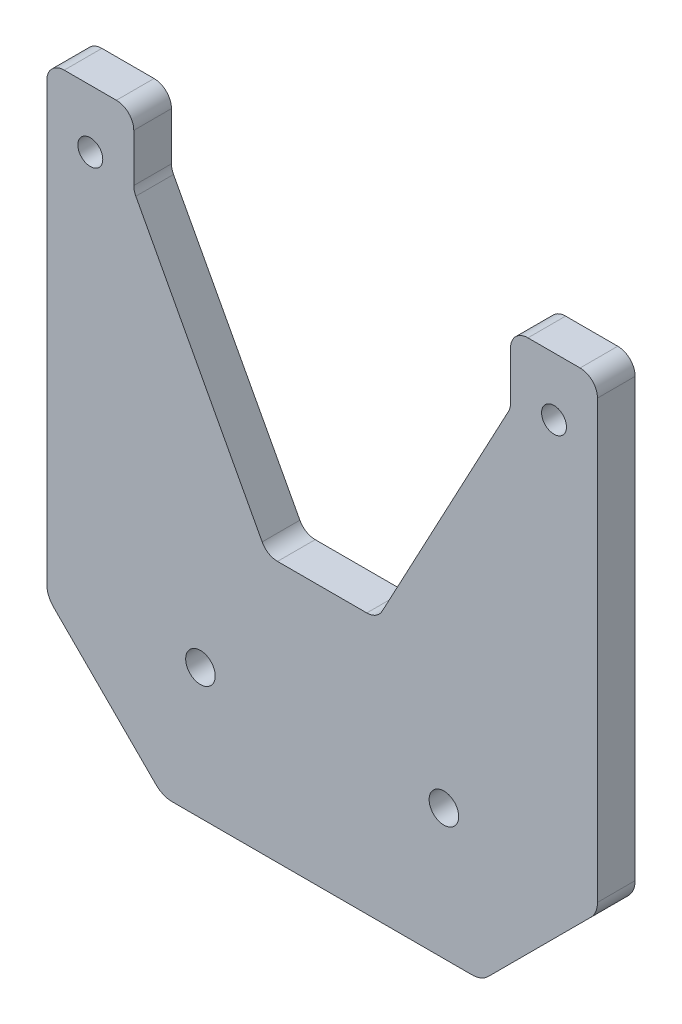
from build123d import *

# Parameters (mm, degrees)
SKETCH1_R           = 2.55
SKETCH1_R_2         = 2.15
BOSS_EXTRUDE1_DEPTH = 6.5
FILLET1_R           = 3
CHAMFER1_SIZE       = 20
FILLET2_R           = 4


with BuildPart() as part:
    # Sketch1 → Boss-Extrude1 (new body)
    with BuildSketch(Plane.XY):
        Polygon((-32.5, 43), (-32.5, 55), (-47.5, 55), (-47.5, -45), (47.5, -45), (47.5, 55), (32.5, 55), (32.5, 43), (9.5, 0), (-9.5, 0), align=None)
        with Locations((-21, -22.5)):
            Circle(SKETCH1_R, mode=Mode.SUBTRACT)
        with Locations((21, -22.5)):
            Circle(SKETCH1_R, mode=Mode.SUBTRACT)
        with Locations((-40, 45)):
            Circle(SKETCH1_R_2, mode=Mode.SUBTRACT)
        with Locations((40, 45)):
            Circle(SKETCH1_R_2, mode=Mode.SUBTRACT)
    extrude(amount=BOSS_EXTRUDE1_DEPTH)

    # Fillet1
    fillet1_edges = [part.edges().sort_by_distance(p)[0] for p in [
        (9.5, 0, 3.25),
        (32.5, 43, 3.25),
        (32.5, 55, 3.25),
        (47.5, 55, 3.25),
        (-47.5, 55, 3.25),
        (-32.5, 55, 3.25),
        (-32.5, 43, 3.25),
        (-9.5, 0, 3.25),
    ]]
    fillet(fillet1_edges, radius=FILLET1_R)

    # Chamfer1
    chamfer1_edges = [part.edges().sort_by_distance(p)[0] for p in [
        (47.5, -45, 3.25),
        (-47.5, -45, 3.25),
    ]]
    chamfer(chamfer1_edges, length=CHAMFER1_SIZE)

    # Fillet2
    fillet2_edges = [part.edges().sort_by_distance(p)[0] for p in [
        (47.5, -25, 3.25),
        (-27.5, -45, 3.25),
        (27.5, -45, 3.25),
        (-47.5, -25, 3.25),
    ]]
    fillet(fillet2_edges, radius=FILLET2_R)


solid = part.part
